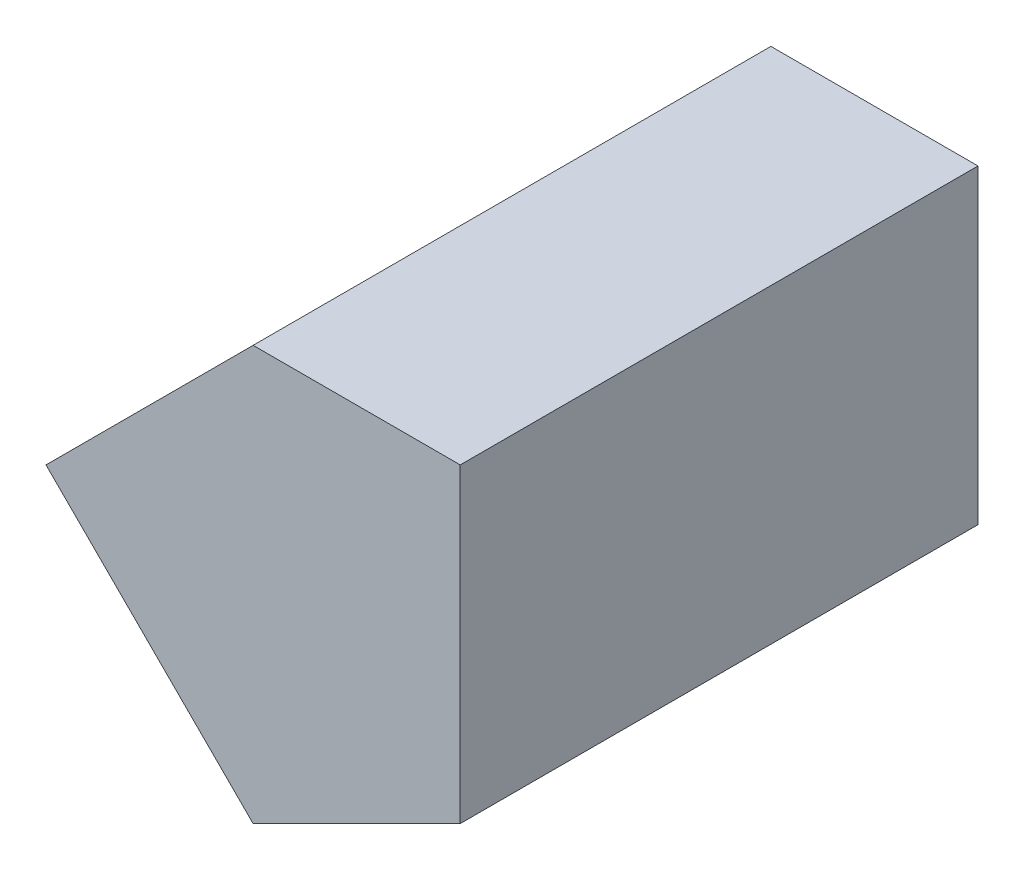
from build123d import *

# Parameters (mm, degrees)
BOSS_EXTRUDE1_DEPTH = 25


with BuildPart() as part:
    # Sketch1 → Boss-Extrude1 (new body)
    with BuildSketch(Plane.XY):
        Polygon((-20, 5), (-10, 15), (0, 15), (0, 0), (-10, -5), align=None)
    extrude(amount=BOSS_EXTRUDE1_DEPTH)


solid = part.part
